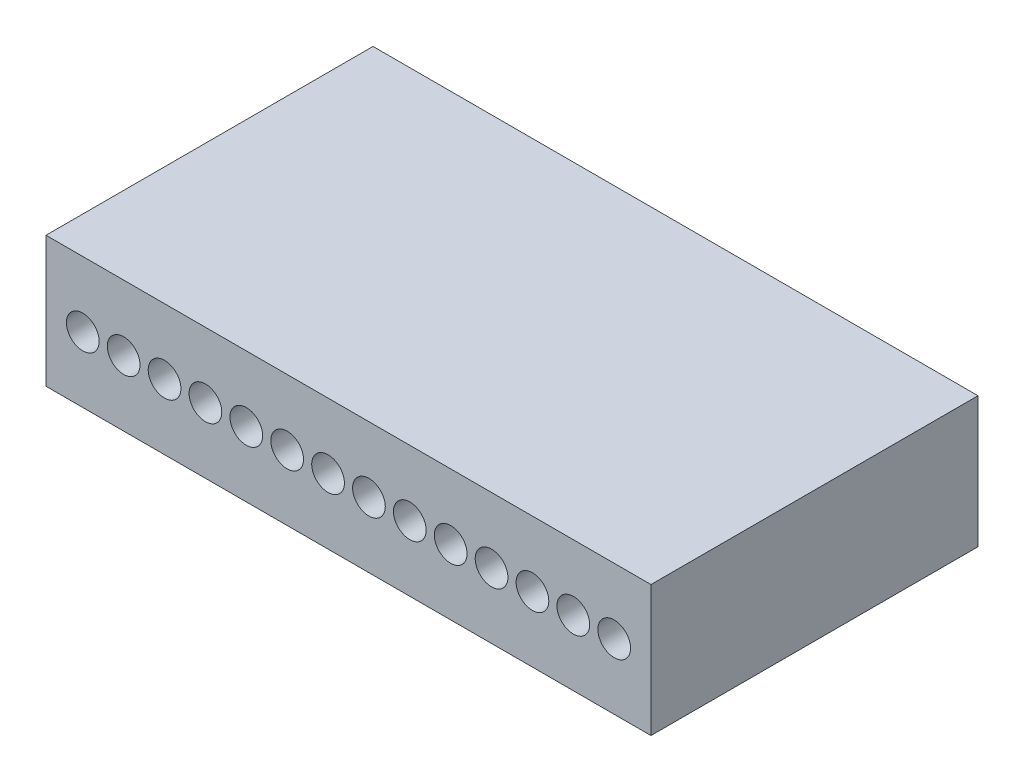
from build123d import *

# Parameters (mm, degrees)
SKETCH2_W           = 18.5
SKETCH2_H           = 4
BOSS_EXTRUDE1_DEPTH = 10
SKETCH3_R           = 0.5
CUT_EXTRUDE1_DEPTH  = 5


with BuildPart() as part:
    # Sketch2 → Boss-Extrude1 (new body)
    with BuildSketch(Plane.XY):
        with Locations((9.25, 2)):
            Rectangle(SKETCH2_W, SKETCH2_H)
    extrude(amount=BOSS_EXTRUDE1_DEPTH)

    # Sketch3 → Cut-Extrude1 (cut)
    with BuildSketch(Plane.XY.offset(10)):
        with Locations((1.125, 2)):
            Circle(SKETCH3_R)
        with Locations((2.375, 2)):
            Circle(SKETCH3_R)
        with Locations((3.625, 2)):
            Circle(SKETCH3_R)
        with Locations((4.875, 2)):
            Circle(SKETCH3_R)
        with Locations((6.125, 2)):
            Circle(SKETCH3_R)
        with Locations((7.375, 2)):
            Circle(SKETCH3_R)
        with Locations((8.625, 2)):
            Circle(SKETCH3_R)
        with Locations((9.875, 2)):
            Circle(SKETCH3_R)
        with Locations((11.125, 2)):
            Circle(SKETCH3_R)
        with Locations((12.375, 2)):
            Circle(SKETCH3_R)
        with Locations((13.625, 2)):
            Circle(SKETCH3_R)
        with Locations((14.875, 2)):
            Circle(SKETCH3_R)
        with Locations((16.125, 2)):
            Circle(SKETCH3_R)
        with Locations((17.375, 2)):
            Circle(SKETCH3_R)
    extrude(amount=-CUT_EXTRUDE1_DEPTH, mode=Mode.SUBTRACT)


solid = part.part
